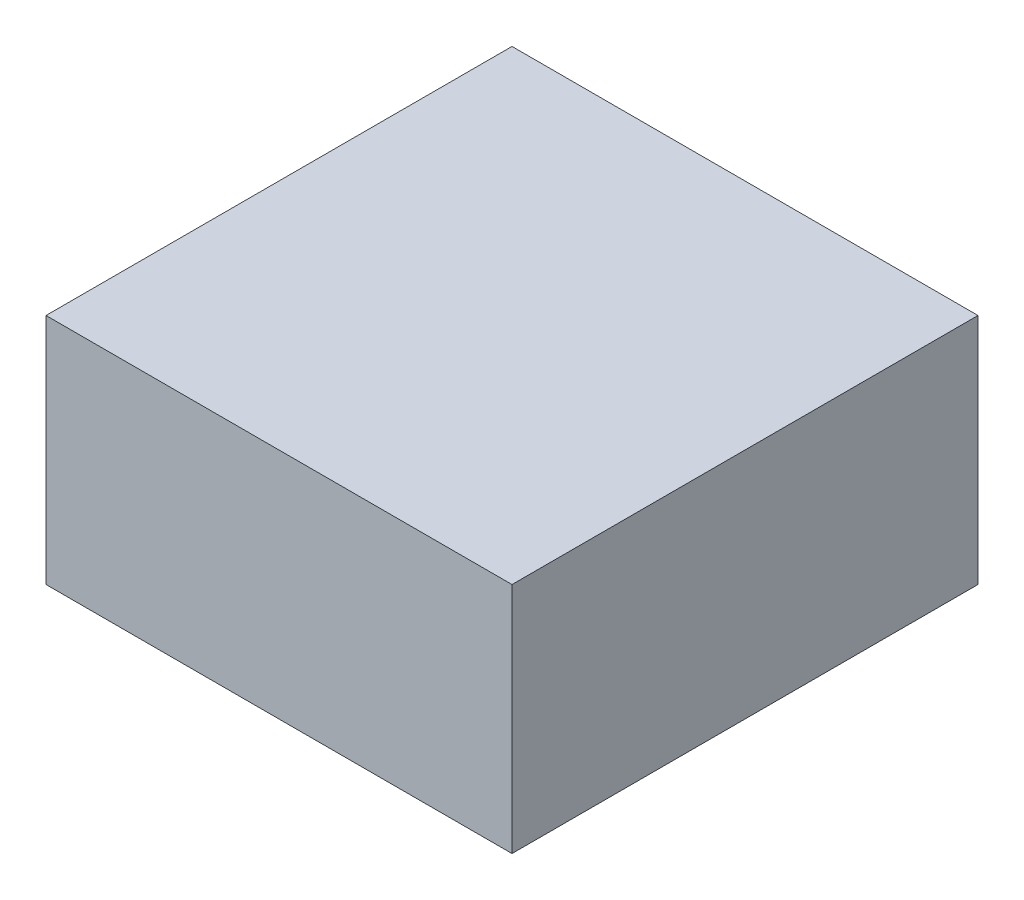
from build123d import *

# Parameters (mm, degrees)
SKETCH1_W           = 100
SKETCH1_H           = 100
BOSS_EXTRUDE1_DEPTH = 50


with BuildPart() as part:
    # Sketch1 → Boss-Extrude1 (new body)
    with BuildSketch(Plane(origin=(0, 0, 0), x_dir=(1, 0, 0), z_dir=(0, 1, 0))):
        with Locations((50, 50)):
            Rectangle(SKETCH1_W, SKETCH1_H)
    extrude(amount=BOSS_EXTRUDE1_DEPTH)


solid = part.part
